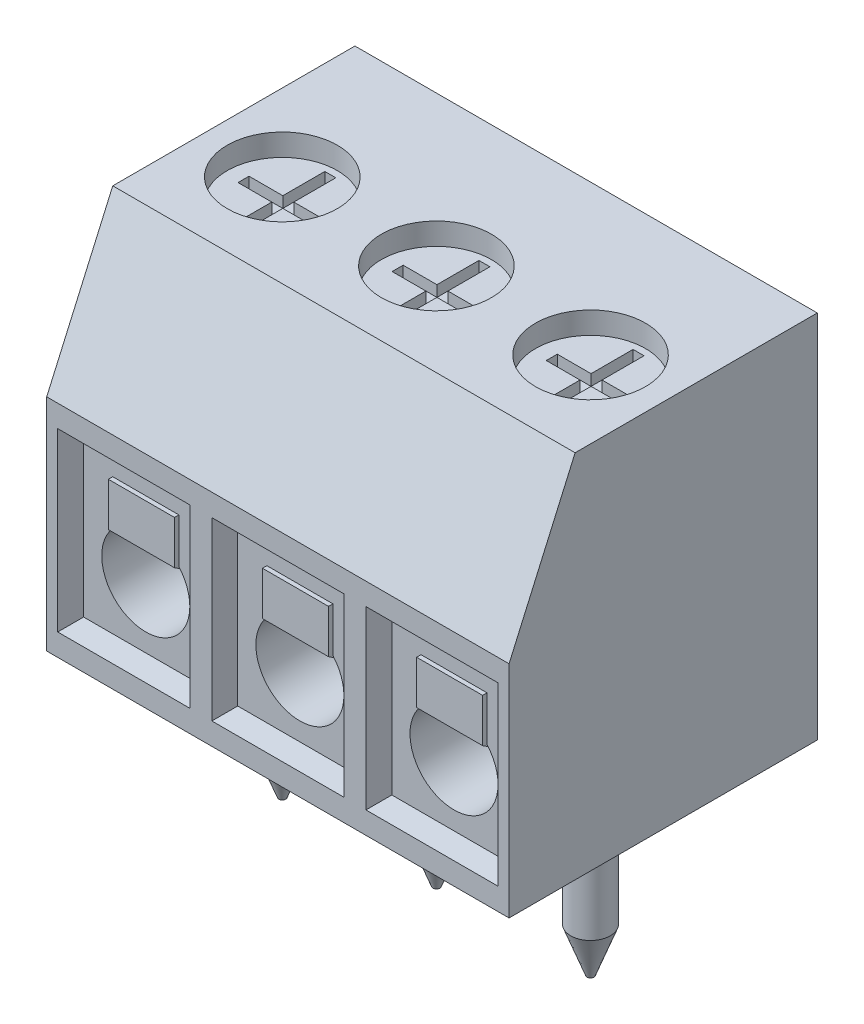
from build123d import *

# Parameters (mm, degrees)
BOSS_EXTRUDE1_DEPTH         = 10.5
SKETCH2_R                   = 1.25
CUT_EXTRUDE1_DEPTH          = 0.5
SKETCH3_W                   = 3
SKETCH3_H                   = 4
CUT_EXTRUDE2_DEPTH          = 0.5
CUT_EXTRUDE2_TAPER          = 10
SKETCH4_R                   = 1
CUT_EXTRUDE3_DEPTH          = 6
SKETCH6_R                   = 0.45
BOSS_EXTRUDE3_DEPTH         = 3.8
CHAMFER1_SIZE               = 1
CHAMFER1_SIZE2              = 0.371896666
EXTRUDE_THIN1_DEPTH         = 0.75
SKETCH8_W                   = 0.25
SKETCH8_H                   = 2.158330758
SKETCH8_W_2                 = 1.874325027
SKETCH8_H_2                 = 0.25
CUT_EXTRUDE_THIN1_DEPTH     = 0.25
LPATTERN1_COUNT             = 3
LPATTERN1_PITCH             = 3.5
CHAMFER1_OF_LPATTERN1_SIZE2 = 0.371896666
CHAMFER1_OF_LPATTERN1_SIZE  = 1


with BuildPart() as part:
    # Sketch1 → Boss-Extrude1 (new body)
    with BuildSketch(Plane(origin=(0, 0, 0), x_dir=(0, 0, -1), z_dir=(1, 0, 0))):
        Polygon((0, 5), (1.5, 8.4), (7, 8.4), (7, 0), (0, 0), align=None)
    extrude(amount=BOSS_EXTRUDE1_DEPTH)

    # Sketch2 → Cut-Extrude1 (cut)
    with BuildSketch(Plane(origin=(0, 8.4, 0), x_dir=(1, 0, 0), z_dir=(0, 1, 0))):
        with Locations((1.75, 3.6)):
            Circle(SKETCH2_R)
    cut_extrude1 = extrude(amount=-CUT_EXTRUDE1_DEPTH, mode=Mode.SUBTRACT)

    # Sketch3 → Cut-Extrude2 (cut)
    with BuildSketch(Plane.XY):
        with Locations((1.75, 2.5)):
            Rectangle(SKETCH3_W, SKETCH3_H)
    cut_extrude2 = extrude(amount=-CUT_EXTRUDE2_DEPTH, taper=CUT_EXTRUDE2_TAPER, mode=Mode.SUBTRACT)

    # Sketch4 → Cut-Extrude3 (cut)
    with BuildSketch(Plane.XY.offset(-0.5)):
        with Locations((1.75, 2)):
            Circle(SKETCH4_R)
    cut_extrude3 = extrude(amount=-CUT_EXTRUDE3_DEPTH, mode=Mode.SUBTRACT)

    # Sketch6 → Boss-Extrude3 (add)
    with BuildSketch(Plane.XZ):
        with Locations((1.75, -3.6)):
            Circle(SKETCH6_R)
    boss_extrude3 = extrude(amount=BOSS_EXTRUDE3_DEPTH)

    # Chamfer1
    chamfer1_edges = [part.edges().sort_by_distance(p)[0] for p in [
        (1.3, -3.8, -3.6),
    ]]
    chamfer1_side = [part.faces().sort_by_distance(p)[0] for p in [
        (1.3, -1.9, -3.6),
    ]]
    chamfer(chamfer1_edges, length=CHAMFER1_SIZE, length2=CHAMFER1_SIZE2, reference=chamfer1_side[0])

    # Sketch7 → Extrude-Thin1 (add, symmetric)
    with BuildSketch(Plane(origin=(1.75, 0, 0), x_dir=(0, 0, -1), z_dir=(1, 0, 0))):
        Polygon((0.5, 3.678716588), (0.5, 2.743158903), (1.89970396, 1.832221158), (5.88813409, 1.438302133), (5.878305368, 1.338786324), (1.865601336, 1.735102771), (0.4, 2.688927019), (0.4, 3.678716588), align=None)
    extrude_thin1 = extrude(amount=EXTRUDE_THIN1_DEPTH, both=True)

    # Sketch8 → Cut-Extrude-Thin1 (cut, symmetric)
    with BuildSketch(Plane(origin=(0, 7.9, 0), x_dir=(1, 0, 0), z_dir=(0, 1, 0))):
        with Locations((1.75, 3.611637798)):
            Rectangle(SKETCH8_W, SKETCH8_H)
        with Locations((1.795143175, 3.611637798)):
            Rectangle(SKETCH8_W_2, SKETCH8_H_2)
    cut_extrude_thin1 = extrude(amount=CUT_EXTRUDE_THIN1_DEPTH, both=True, mode=Mode.SUBTRACT)

    # LPattern1: Cut-Extrude1, Cut-Extrude2, Cut-Extrude3, Boss-Extrude3, Extrude-Thin1, Cut-Extrude-Thin1 ×3
    with Locations(*[(i * LPATTERN1_PITCH, 0, 0) for i in range(1, LPATTERN1_COUNT)]):
        add(cut_extrude1, mode=Mode.SUBTRACT)
        add(cut_extrude2, mode=Mode.SUBTRACT)
        add(cut_extrude3, mode=Mode.SUBTRACT)
        add(boss_extrude3)
        add(extrude_thin1)
        add(cut_extrude_thin1, mode=Mode.SUBTRACT)

    # Chamfer1 of LPattern1
    chamfer1_of_lpattern1_edges = [part.edges().sort_by_distance(p)[0] for p in [
        (4.8, -3.8, -3.6),
        (8.3, -3.8, -3.6),
    ]]
    chamfer(chamfer1_of_lpattern1_edges, length=CHAMFER1_OF_LPATTERN1_SIZE, length2=CHAMFER1_OF_LPATTERN1_SIZE2)


solid = part.part
